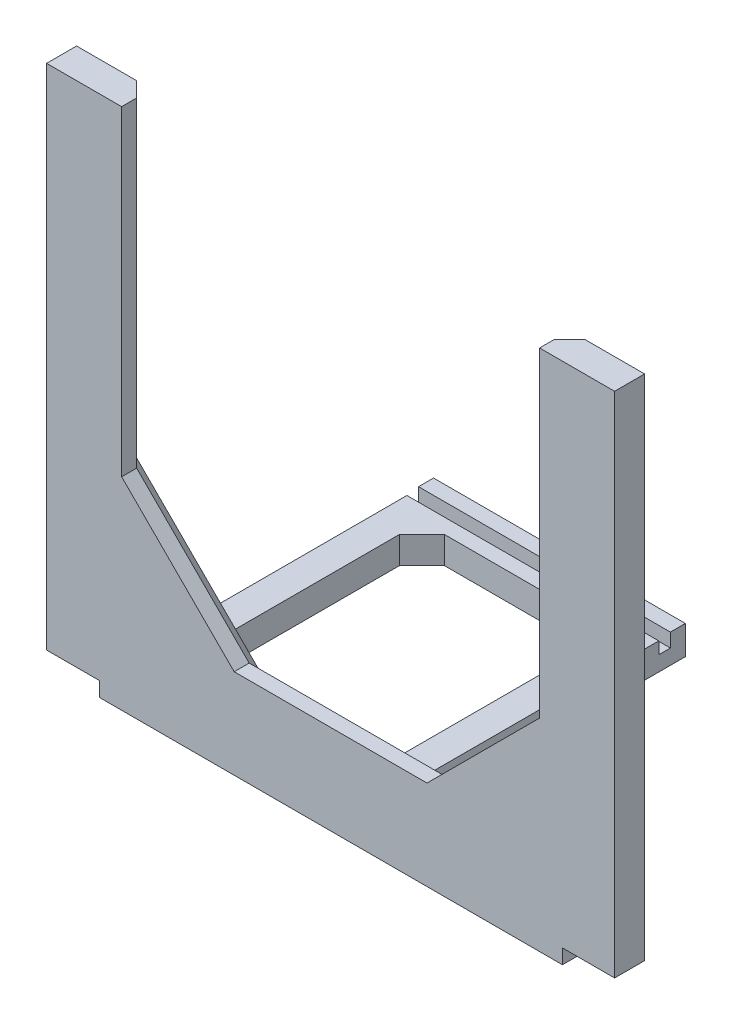
from build123d import *

# Parameters (mm, degrees)
SKETCH6_W           = 33.56421262
SKETCH6_H           = 1.838759269
BOSS_EXTRUDE3_DEPTH = 2
SKETCH7_W           = 33.56421262
SKETCH7_H           = 5.55
BOSS_EXTRUDE4_DEPTH = 2
SKETCH8_W           = 2
SKETCH8_H           = 1.6
BOSS_EXTRUDE5_DEPTH = 33.56421262
SKETCH9_W           = 4
SKETCH9_H           = 3.6
BOSS_EXTRUDE6_DEPTH = 38.203681183
BOSS_EXTRUDE7_DEPTH = 4
CHAMFER2_SIZE       = 3
CHAMFER5_SIZE       = 15
SKETCH11_R          = 1.7
CUT_EXTRUDE1_DEPTH  = 3
CHAMFER7_SIZE       = 2


with BuildPart() as part:
    # Sketch6 → Boss-Extrude3 (new body)
    with BuildSketch(Plane(origin=(0, 0, -103.809020593), x_dir=(-1, 0, 0), z_dir=(0, 0, -1))):
        with Locations((54.699348296, -69.800699844)):
            Rectangle(SKETCH6_W, SKETCH6_H)
    extrude(amount=BOSS_EXTRUDE3_DEPTH)

    # Sketch7 → Boss-Extrude4 (add)
    with BuildSketch(Plane.XZ.offset(70.720079478)):
        with Locations((-54.699348296, -103.034020593)):
            Rectangle(SKETCH7_W, SKETCH7_H)
    extrude(amount=BOSS_EXTRUDE4_DEPTH)

    # Sketch8 → Boss-Extrude5 (add)
    with BuildSketch(Plane(origin=(-37.917241986, 0, 0), x_dir=(0, 0, -1), z_dir=(1, 0, 0))):
        with Locations((101.259020593, -69.920079478)):
            Rectangle(SKETCH8_W, SKETCH8_H)
    extrude(amount=-BOSS_EXTRUDE5_DEPTH)

    # Sketch9 → Boss-Extrude6 (add)
    with BuildSketch(Plane.XY.offset(-100.259020593)):
        with Locations((-69.481454606, -70.920079478)):
            Rectangle(SKETCH9_W, SKETCH9_H)
        with Locations((-39.917241986, -70.920079478)):
            Rectangle(SKETCH9_W, SKETCH9_H)
    extrude(amount=BOSS_EXTRUDE6_DEPTH)

    # Sketch10 → Boss-Extrude7 (add)
    with BuildSketch(Plane.XY.offset(-62.055339411)):
        Polygon((-79.3, -70.770079478), (-72.25, -70.770079478), (-72.25, -72.720079478), (-71.481454606, -72.720079478), (-71.481454606, -69.120079478), (-67.481454606, -69.120079478), (-67.481454606, -72.720079478), (-41.917241986, -72.720079478), (-41.917241986, -69.120079478), (-37.917241986, -69.120079478), (-37.917241986, -72.720079478), (-10.55, -72.720079478), (-10.55, -70.770079478), (-3.6, -70.770079478), (-3.6, -3.05), (-13.6, -3.05), (-13.600000688, -60.770079478), (-69.3, -60.770079478), (-69.3, -3.05), (-79.3, -3.05), align=None)
    extrude(amount=-BOSS_EXTRUDE7_DEPTH)

    # Chamfer2
    chamfer2_edges = [part.edges().sort_by_distance(p)[0] for p in [
        (-41.917241986, -70.920079478, -100.259020593),
        (-67.481454606, -70.920079478, -100.259020593),
        (-41.917241986, -70.920079478, -66.055339411),
        (-39.917241986, -69.120079478, -66.055339411),
        (-37.917241986, -70.920079478, -66.055339411),
        (-67.481454606, -70.920079478, -66.055339411),
        (-69.481454606, -69.120079478, -66.055339411),
        (-71.481454606, -70.920079478, -66.055339411),
    ]]
    chamfer(chamfer2_edges, length=CHAMFER2_SIZE)

    # Chamfer5
    chamfer5_edges = [part.edges().sort_by_distance(p)[0] for p in [
        (-69.3, -60.770079478, -64.055339411),
        (-13.600000688, -60.770079478, -64.055339411),
    ]]
    chamfer(chamfer5_edges, length=CHAMFER5_SIZE)

    # Sketch11 → Cut-Extrude1 (cut)
    with BuildSketch(Plane(origin=(0, 0, -66.055339411), x_dir=(-1, 0, 0), z_dir=(0, 0, -1))):
        with Locations((8.6, -6.55)):
            Circle(SKETCH11_R)
        with Locations((74.3, -6.55)):
            Circle(SKETCH11_R)
    extrude(amount=-CUT_EXTRUDE1_DEPTH, mode=Mode.SUBTRACT)

    # Chamfer7
    chamfer7_edges = [part.edges().sort_by_distance(p)[0] for p in [
        (-41.450000344, -60.770079478, -66.055339411),
        (-21.100000599, -53.270079478, -66.055339411),
        (-61.8, -53.270079478, -66.055339411),
        (-69.3, -24.410039739, -66.055339411),
        (-13.600000255, -24.410039739, -66.055339411),
    ]]
    chamfer(chamfer7_edges, length=CHAMFER7_SIZE)


solid = part.part
